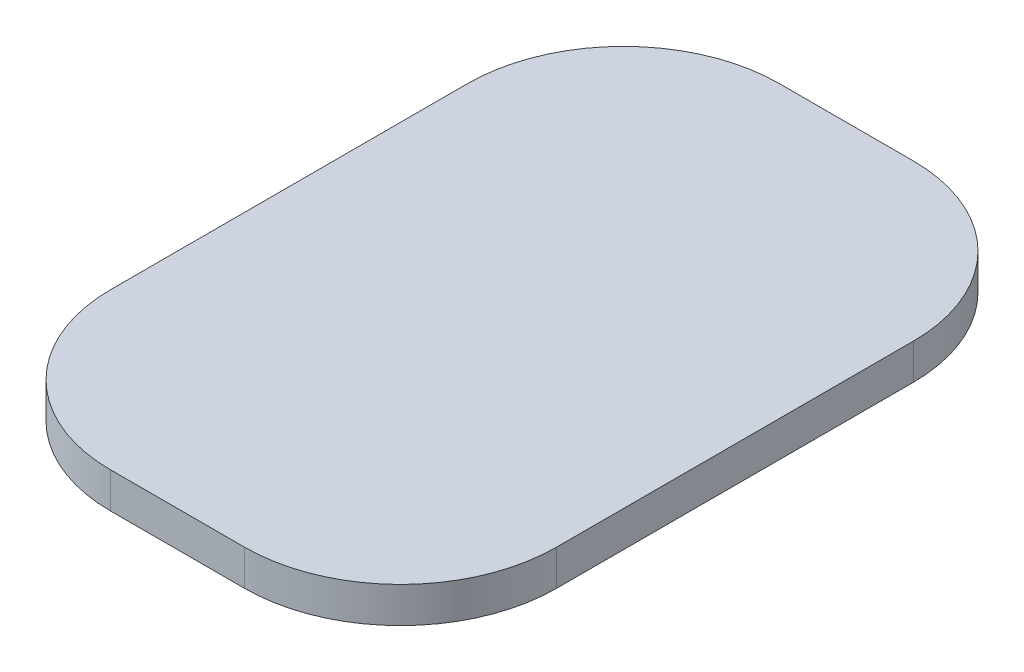
from build123d import *

# Parameters (mm, degrees)
SKETCH1_W           = 100
SKETCH1_H           = 150
BOSS_EXTRUDE1_DEPTH = 8
FILLET1_R           = 35


with BuildPart() as part:
    # Sketch1 → Boss-Extrude1 (new body)
    with BuildSketch(Plane(origin=(0, 0, 0), x_dir=(1, 0, 0), z_dir=(0, 1, 0))):
        with Locations((-28.338278932, -5.341246291)):
            Rectangle(SKETCH1_W, SKETCH1_H)
    extrude(amount=BOSS_EXTRUDE1_DEPTH)

    # Fillet1
    fillet1_edges = [part.edges().sort_by_distance(p)[0] for p in [
        (-78.338278932, 4, -69.658753709),
        (21.661721068, 4, -69.658753709),
        (21.661721068, 4, 80.341246291),
        (-78.338278932, 4, 80.341246291),
    ]]
    fillet(fillet1_edges, radius=FILLET1_R)


solid = part.part
